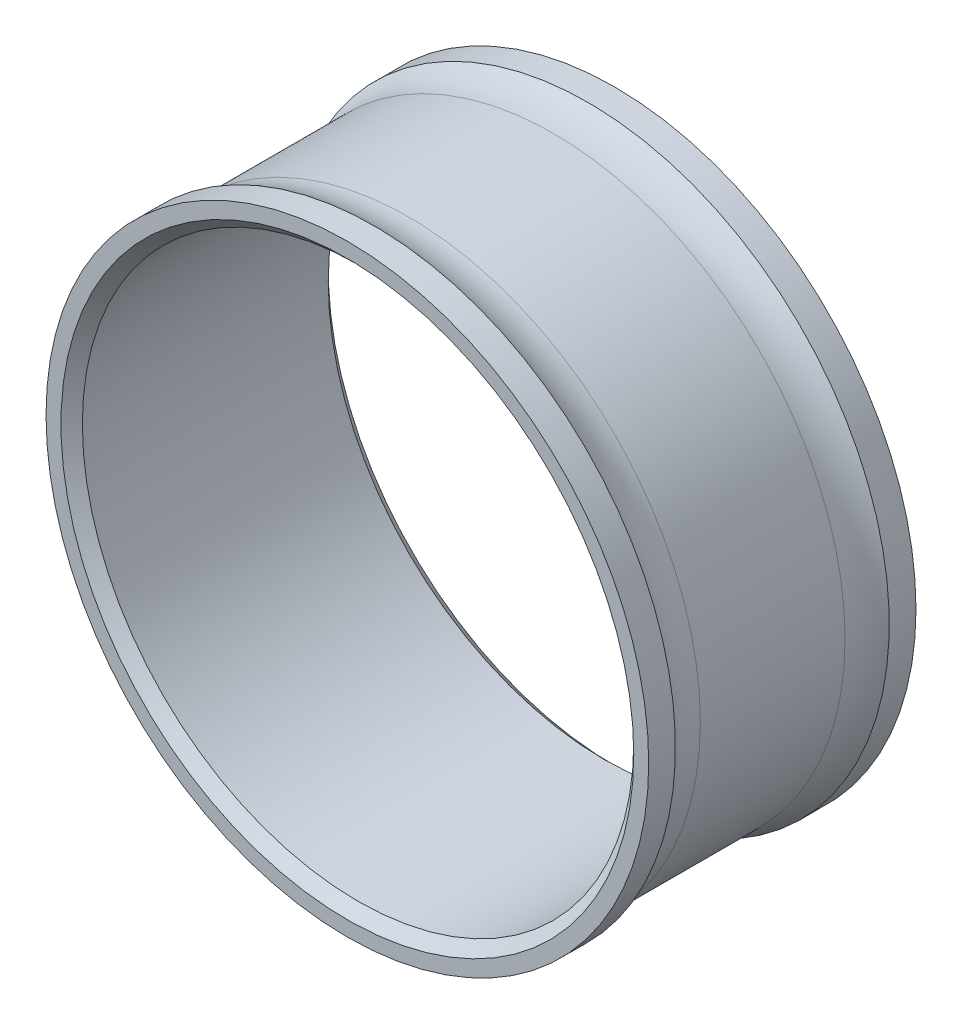
from build123d import *

# Parameters (mm, degrees)
SKETCH1_R           = 35.8013
SKETCH1_R_2         = 32.754
BOSS_EXTRUDE1_DEPTH = 15.875
CHAMFER1_SIZE       = 1.27


with BuildPart() as part:
    # Sketch1 → Boss-Extrude1 (new body, symmetric)
    with BuildSketch(Plane.XY):
        Circle(SKETCH1_R)
        Circle(SKETCH1_R_2, mode=Mode.SUBTRACT)
    extrude(amount=BOSS_EXTRUDE1_DEPTH, both=True)

    # Chamfer1
    chamfer1_edges = [part.edges().sort_by_distance(p)[0] for p in [
        (-32.754, 0, -15.875),
        (-32.754, 0, 15.875),
    ]]
    chamfer(chamfer1_edges, length=CHAMFER1_SIZE)

    # Sketch6 → Cut-Revolve2 (revolve, cut)
    with BuildSketch(Plane(origin=(0, 0, 0), x_dir=(1, 0, 0), z_dir=(0, 1, 0))):
        with BuildLine():
            Line((34.659, -8.597663689), (34.659, 8.597663689))
            ThreePointArc((34.659, 8.597663689), (34.949905783, 10.726866151), (35.8013, 12.7))
            Line((35.8013, 12.7), (35.8013, -12.7))
            ThreePointArc((35.8013, -12.7), (34.949905783, -10.726866151), (34.659, -8.597663689))
        make_face()
    revolve(axis=Axis((0, 0, -15.875), (0, 0, 1)), mode=Mode.SUBTRACT)


solid = part.part
